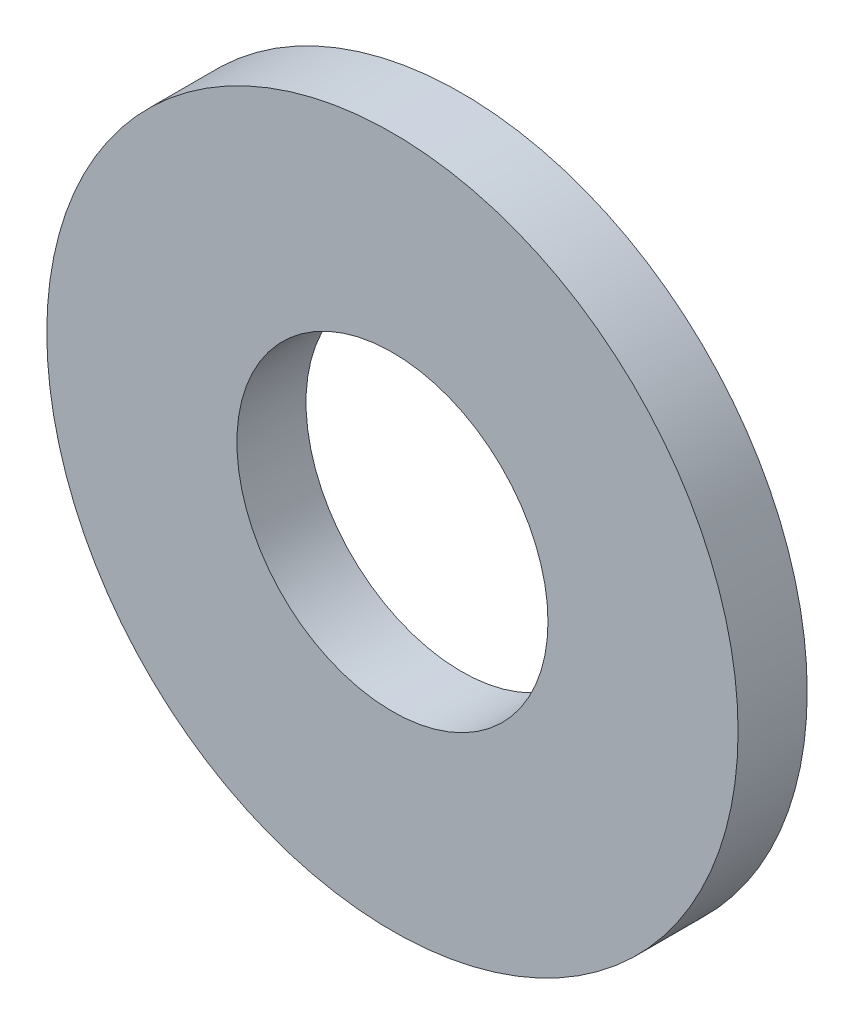
from build123d import *

# Parameters (mm, degrees)
SKETCH1_R           = 3
SKETCH1_R_2         = 1.35
BOSS_EXTRUDE1_DEPTH = 0.6


with BuildPart() as part:
    # Sketch1 → Boss-Extrude1 (new body)
    with BuildSketch(Plane.XY):
        Circle(SKETCH1_R)
        Circle(SKETCH1_R_2, mode=Mode.SUBTRACT)
    extrude(amount=BOSS_EXTRUDE1_DEPTH)


solid = part.part
